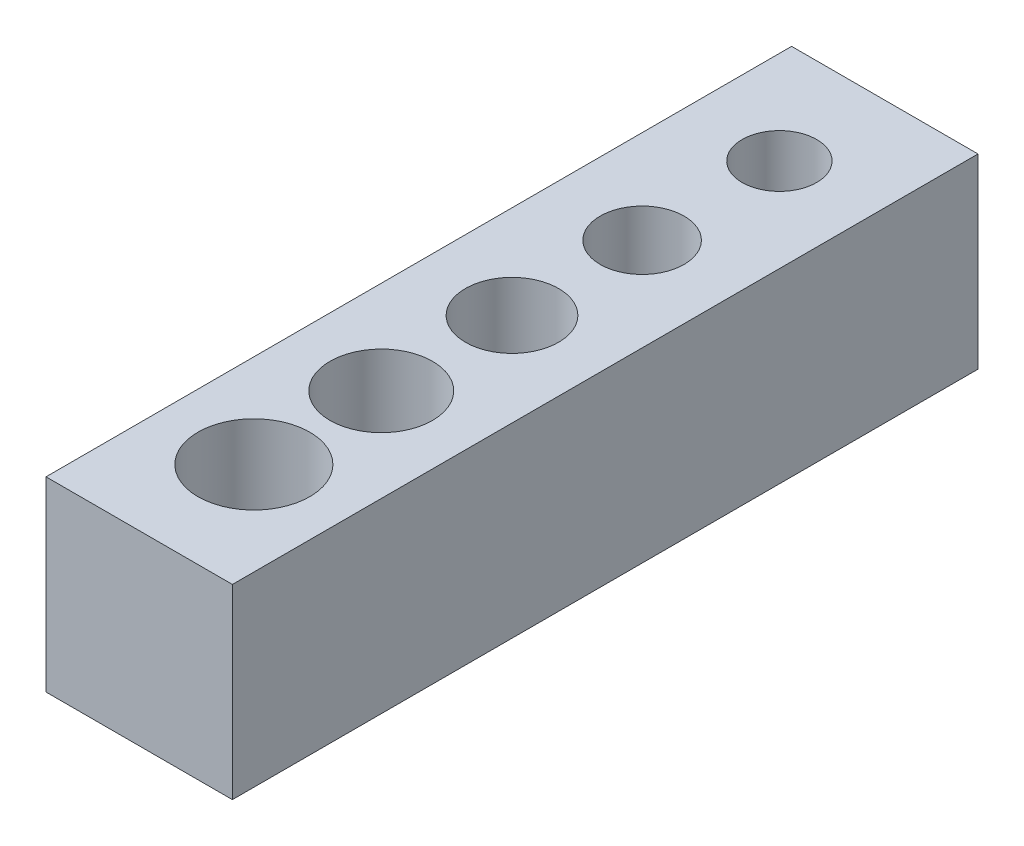
from build123d import *

# Parameters (mm, degrees)
SKETCH1_W           = 10
SKETCH1_H           = 40
SKETCH1_R           = 2.5
SKETCH1_R_2         = 2.25
SKETCH1_R_3         = 2.75
SKETCH1_R_4         = 2
SKETCH1_R_5         = 3
BOSS_EXTRUDE1_DEPTH = 10


with BuildPart() as part:
    # Sketch1 → Boss-Extrude1 (new body)
    with BuildSketch(Plane(origin=(0, 0, 0), x_dir=(1, 0, 0), z_dir=(0, 1, 0))):
        Rectangle(SKETCH1_W, SKETCH1_H)
        Circle(SKETCH1_R, mode=Mode.SUBTRACT)
        with Locations((0, 6.981082258)):
            Circle(SKETCH1_R_2, mode=Mode.SUBTRACT)
        with Locations((0, -7.013907219)):
            Circle(SKETCH1_R_3, mode=Mode.SUBTRACT)
        with Locations((0, 14.345399557)):
            Circle(SKETCH1_R_4, mode=Mode.SUBTRACT)
        with Locations((0, -13.848776929)):
            Circle(SKETCH1_R_5, mode=Mode.SUBTRACT)
    extrude(amount=BOSS_EXTRUDE1_DEPTH)


solid = part.part
